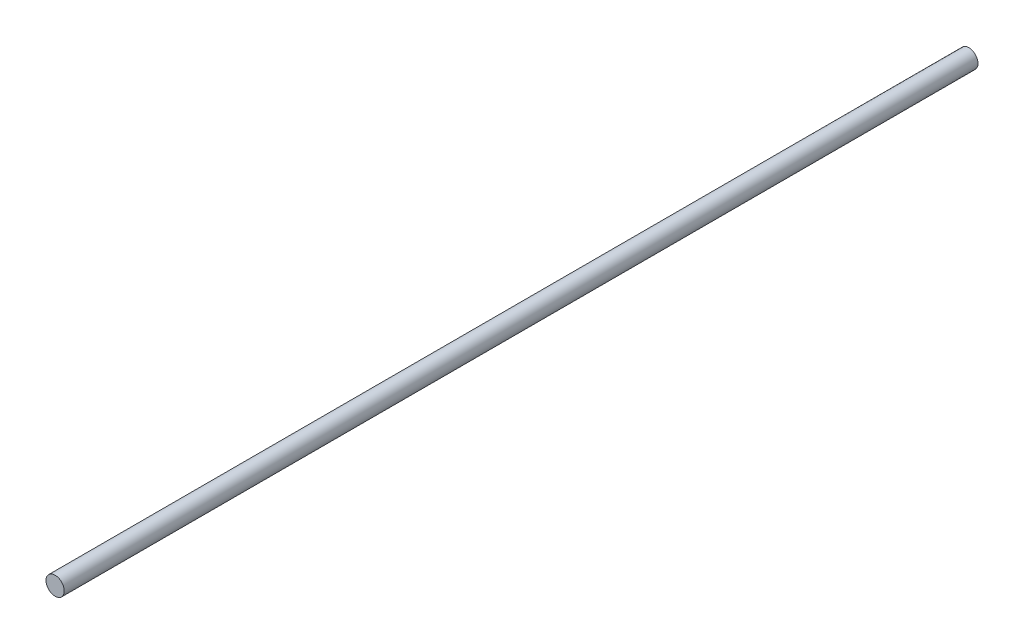
from build123d import *

# Parameters (mm, degrees)
SKETCH_2_R      = 2
EXTRUDE_1_DEPTH = 200


with BuildPart() as part:
    # 草图2 → 凸台-拉伸1 (new body)
    with BuildSketch(Plane.XY):
        Circle(SKETCH_2_R)
    extrude(amount=EXTRUDE_1_DEPTH)


solid = part.part
